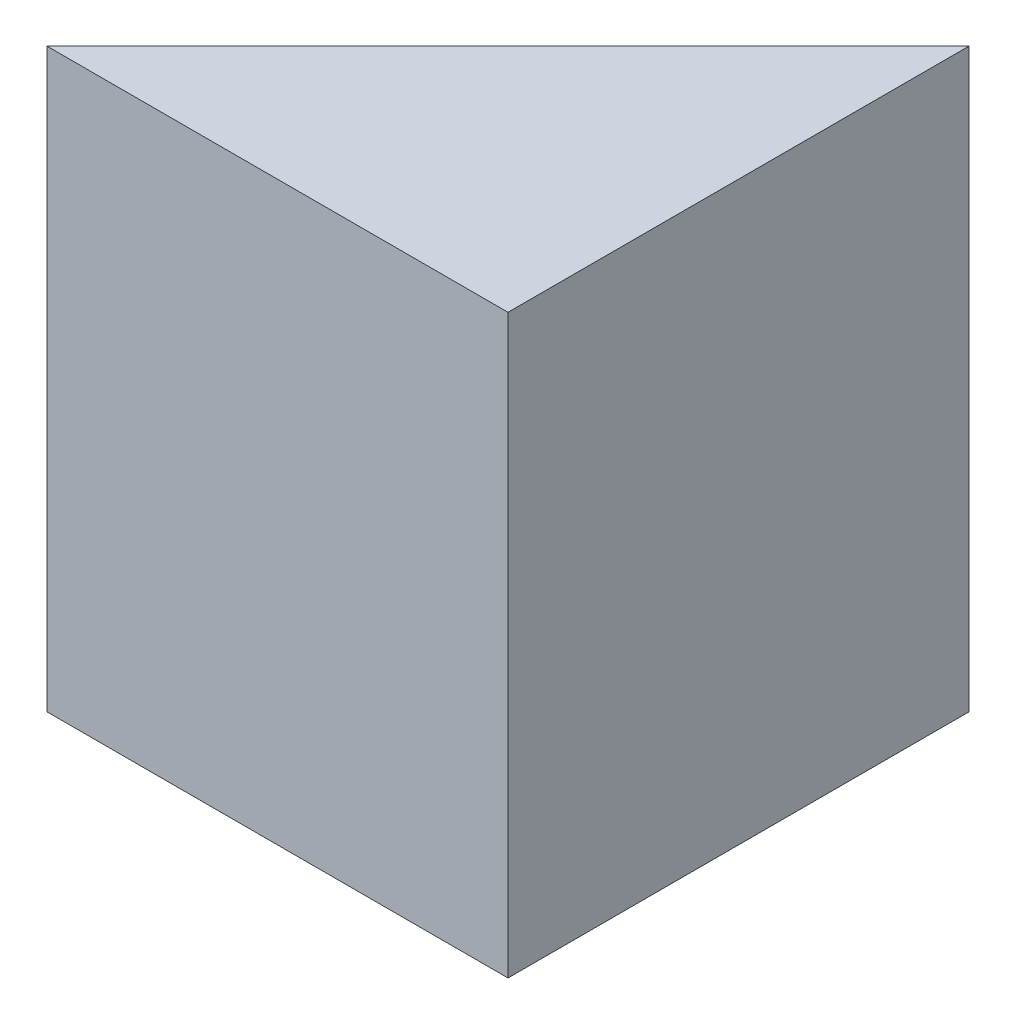
from build123d import *

# Parameters (mm, degrees)
BOSS_EXTRUDE1_DEPTH = 50


with BuildPart() as part:
    # Sketch1 → Boss-Extrude1 (new body)
    with BuildSketch(Plane(origin=(0, 0, 0), x_dir=(1, 0, 0), z_dir=(0, 1, 0))):
        Polygon((0, 0), (40, 0), (40, 40), align=None)
    extrude(amount=BOSS_EXTRUDE1_DEPTH)


solid = part.part
